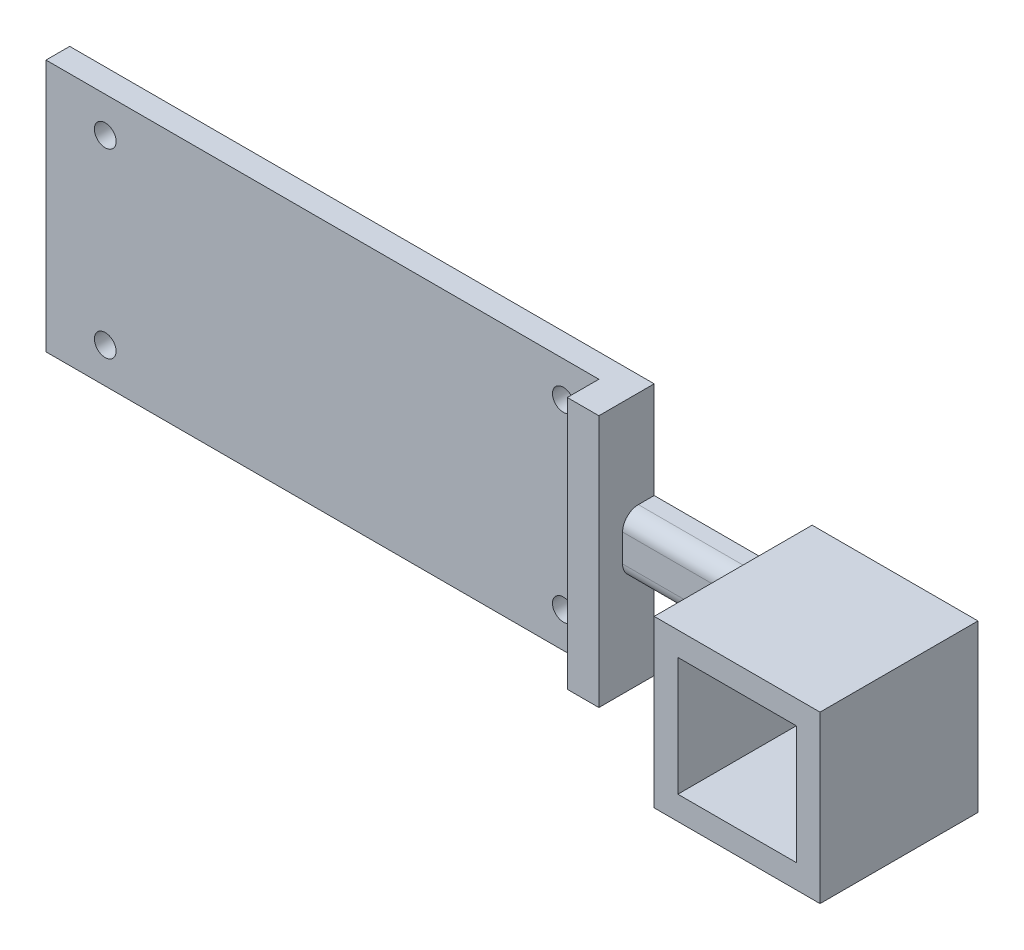
from build123d import *

# Parameters (mm, degrees)
SKETCH2_W           = 21
SKETCH2_H           = 21
BOSS_EXTRUDE1_DEPTH = 20
SKETCH3_W           = 15
SKETCH3_H           = 15
CUT_EXTRUDE1_DEPTH  = 20
SKETCH4_W           = 4
SKETCH4_H           = 7.5
BOSS_EXTRUDE2_DEPTH = 20
FILLET2_R           = 2
SKETCH5_W           = 7
SKETCH5_H           = 32
BOSS_EXTRUDE3_DEPTH = 4
SKETCH6_W           = 3
SKETCH6_H           = 32
BOSS_EXTRUDE4_DEPTH = 70
SKETCH8_R           = 1.375
CUT_EXTRUDE2_DEPTH  = 4


with BuildPart() as part:
    # Sketch2 → Boss-Extrude1 (new body)
    with BuildSketch(Plane.XY):
        Rectangle(SKETCH2_W, SKETCH2_H)
    extrude(amount=BOSS_EXTRUDE1_DEPTH)

    # Sketch3 → Cut-Extrude1 (cut)
    with BuildSketch(Plane.XY.offset(20)):
        Rectangle(SKETCH3_W, SKETCH3_H)
    extrude(amount=-CUT_EXTRUDE1_DEPTH, mode=Mode.SUBTRACT)

    # Sketch4 → Boss-Extrude2 (add)
    with BuildSketch(Plane.ZY.offset(10.5)):
        with Locations((2, 0)):
            Rectangle(SKETCH4_W, SKETCH4_H)
    extrude(amount=BOSS_EXTRUDE2_DEPTH)

    # Fillet2
    fillet2_edges = [part.edges().sort_by_distance(p)[0] for p in [
        (-20.5, -3.75, 4),
        (-20.5, 3.75, 4),
    ]]
    fillet(fillet2_edges, radius=FILLET2_R)

    # Sketch5 → Boss-Extrude3 (add)
    with BuildSketch(Plane.ZY.offset(30.5)):
        with Locations((3.5, 0)):
            Rectangle(SKETCH5_W, SKETCH5_H)
    extrude(amount=BOSS_EXTRUDE3_DEPTH)

    # Sketch6 → Boss-Extrude4 (add)
    with BuildSketch(Plane.ZY.offset(34.5)):
        with Locations((1.5, 0)):
            Rectangle(SKETCH6_W, SKETCH6_H)
    extrude(amount=BOSS_EXTRUDE4_DEPTH)

    # Sketch8 → Cut-Extrude2 (cut)
    with BuildSketch(Plane.XY.offset(3)):
        with Locations((-39, -11.5)):
            Circle(SKETCH8_R)
        with Locations((-39, 11.5)):
            Circle(SKETCH8_R)
        with Locations((-97, -11.5)):
            Circle(SKETCH8_R)
        with Locations((-97, 11.5)):
            Circle(SKETCH8_R)
    extrude(amount=-CUT_EXTRUDE2_DEPTH, mode=Mode.SUBTRACT)


solid = part.part
